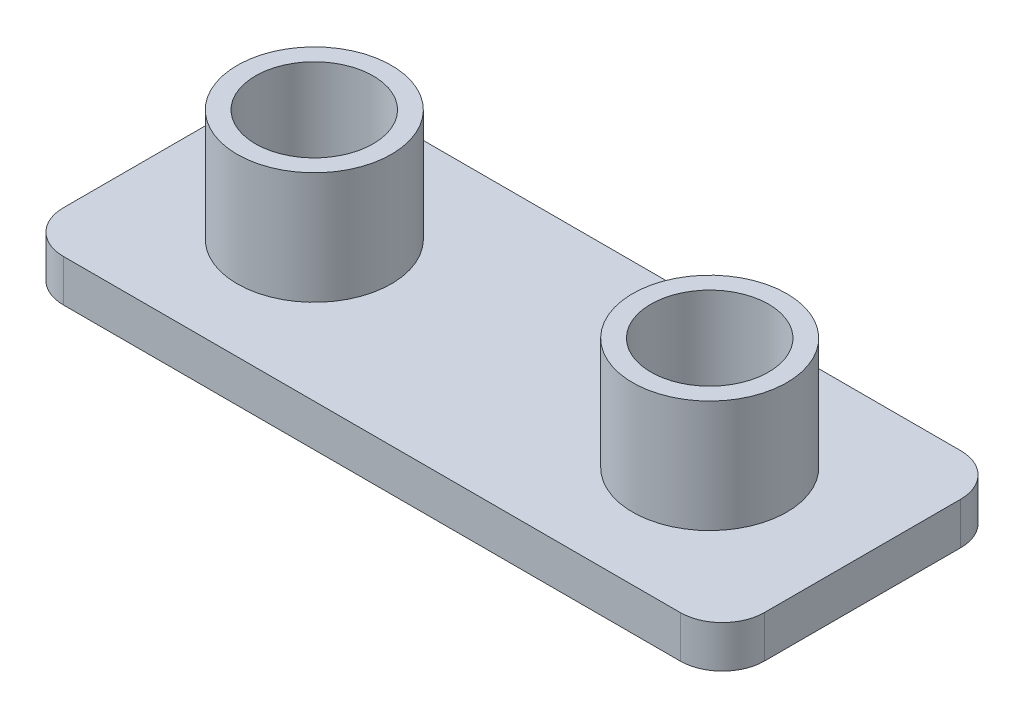
from build123d import *

# Parameters (mm, degrees)
SKETCH1_R           = 2.1
BOSS_EXTRUDE1_DEPTH = 1.5
SKETCH3_R           = 2.75
SKETCH3_R_2         = 2.1
BOSS_EXTRUDE2_DEPTH = 4


with BuildPart() as part:
    # Sketch1 → Boss-Extrude1 (new body)
    with BuildSketch(Plane(origin=(0, 0, 0), x_dir=(1, 0, 0), z_dir=(0, 1, 0))):
        with BuildLine():
            Line((-11, 5), (11, 5))
            ThreePointArc((11, 5), (12.060660172, 4.560660172), (12.5, 3.5))
            Line((12.5, 3.5), (12.5, -3.5))
            ThreePointArc((12.5, -3.5), (12.060660172, -4.560660172), (11, -5))
            Line((11, -5), (-11, -5))
            ThreePointArc((-11, -5), (-12.060660172, -4.560660172), (-12.5, -3.5))
            Line((-12.5, -3.5), (-12.5, 3.5))
            ThreePointArc((-12.5, 3.5), (-12.060660172, 4.560660172), (-11, 5))
        make_face()
        with Locations((-7.05, 0)):
            Circle(SKETCH1_R, mode=Mode.SUBTRACT)
        with Locations((7.05, 0)):
            Circle(SKETCH1_R, mode=Mode.SUBTRACT)
    extrude(amount=BOSS_EXTRUDE1_DEPTH)

    # Sketch3 → Boss-Extrude2 (add)
    with BuildSketch(Plane(origin=(0, 1.5, 0), x_dir=(1, 0, 0), z_dir=(0, 1, 0))):
        with Locations((-7.05, 0)):
            Circle(SKETCH3_R)
        with Locations((-7.05, 0)):
            Circle(SKETCH3_R_2, mode=Mode.SUBTRACT)
        with Locations((7.05, 0)):
            Circle(SKETCH3_R)
        with Locations((7.05, 0)):
            Circle(SKETCH3_R_2, mode=Mode.SUBTRACT)
    extrude(amount=BOSS_EXTRUDE2_DEPTH)


solid = part.part
